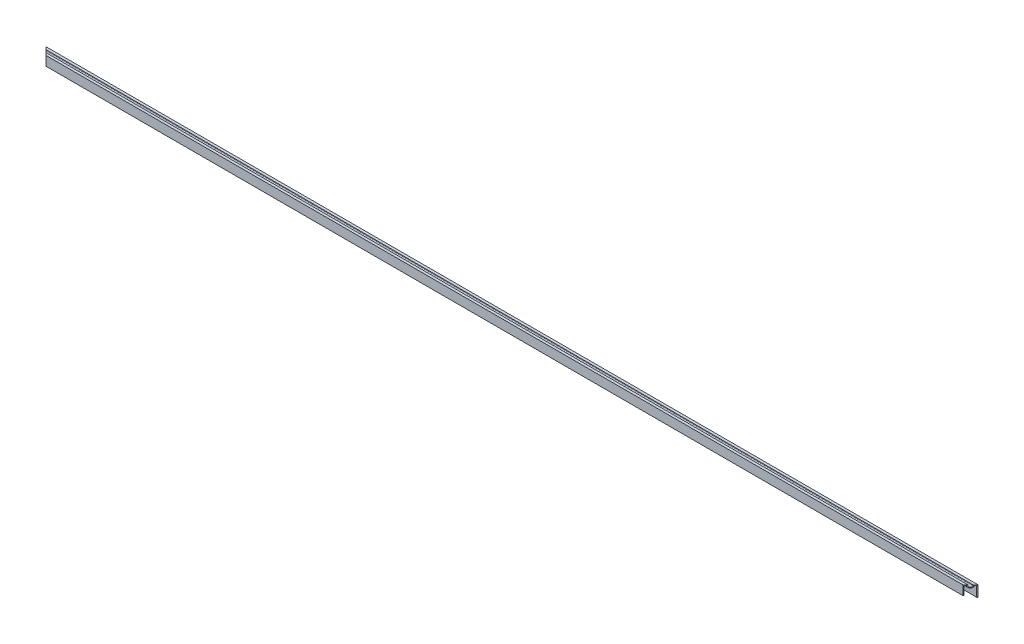
from build123d import *

# Parameters (mm, degrees)
BOSS_EXTRUDE1_DEPTH       = 934.24375
CUT_TOP_RIGHT_FRONT_DEPTH = 22.844
CUT_TOP_LEFT_FRONT_DEPTH  = 22.844


with BuildPart() as part:
    # Sketch1 → Boss-Extrude1 (new body, symmetric)
    with BuildSketch(Plane(origin=(0, 0, 0), x_dir=(0, 0, -1), z_dir=(1, 0, 0))):
        with BuildLine():
            Line((0, 0), (0, 21.844))
            Line((0, 21.844), (-5.08, 21.844))
            Line((-5.08, 21.844), (-5.08, 20.066))
            ThreePointArc((-5.08, 20.066), (-7.62, 17.526), (-10.16, 20.066))
            Line((-10.16, 20.066), (-10.16, 21.844))
            Line((-10.16, 21.844), (-15.24, 21.844))
            Line((-15.24, 21.844), (-15.24, 3.048))
            Line((-15.24, 3.048), (-13.97, 3.048))
            Line((-13.97, 3.048), (-13.97, 20.574))
            Line((-13.97, 20.574), (-11.43, 20.574))
            Line((-11.43, 20.574), (-11.43, 20.066))
            ThreePointArc((-11.43, 20.066), (-7.62, 16.256), (-3.81, 20.066))
            Line((-3.81, 20.066), (-3.81, 20.574))
            Line((-3.81, 20.574), (-1.27, 20.574))
            Line((-1.27, 20.574), (-1.27, 0))
            Line((-1.27, 0), (0, 0))
        make_face()
    extrude(amount=BOSS_EXTRUDE1_DEPTH, both=True)

    # Sketch2 → Cut-Top-Right-Front (cut, through all)
    with BuildSketch(Plane(origin=(0, 21.844, 0), x_dir=(1, 0, 0), z_dir=(0, 1, 0))):
        Polygon((934.24375, 0), (919.00375, -15.24), (934.24375, -15.24), align=None)
    extrude(amount=-CUT_TOP_RIGHT_FRONT_DEPTH, mode=Mode.SUBTRACT)

    # Sketch4 → Cut-Top-Left-Front (cut, through all)
    with BuildSketch(Plane(origin=(0, 21.844, 0), x_dir=(1, 0, 0), z_dir=(0, 1, 0))):
        Polygon((-934.24375, 0), (-919.00375, -15.24), (-934.24375, -15.24), align=None)
    extrude(amount=-CUT_TOP_LEFT_FRONT_DEPTH, mode=Mode.SUBTRACT)


solid = part.part
